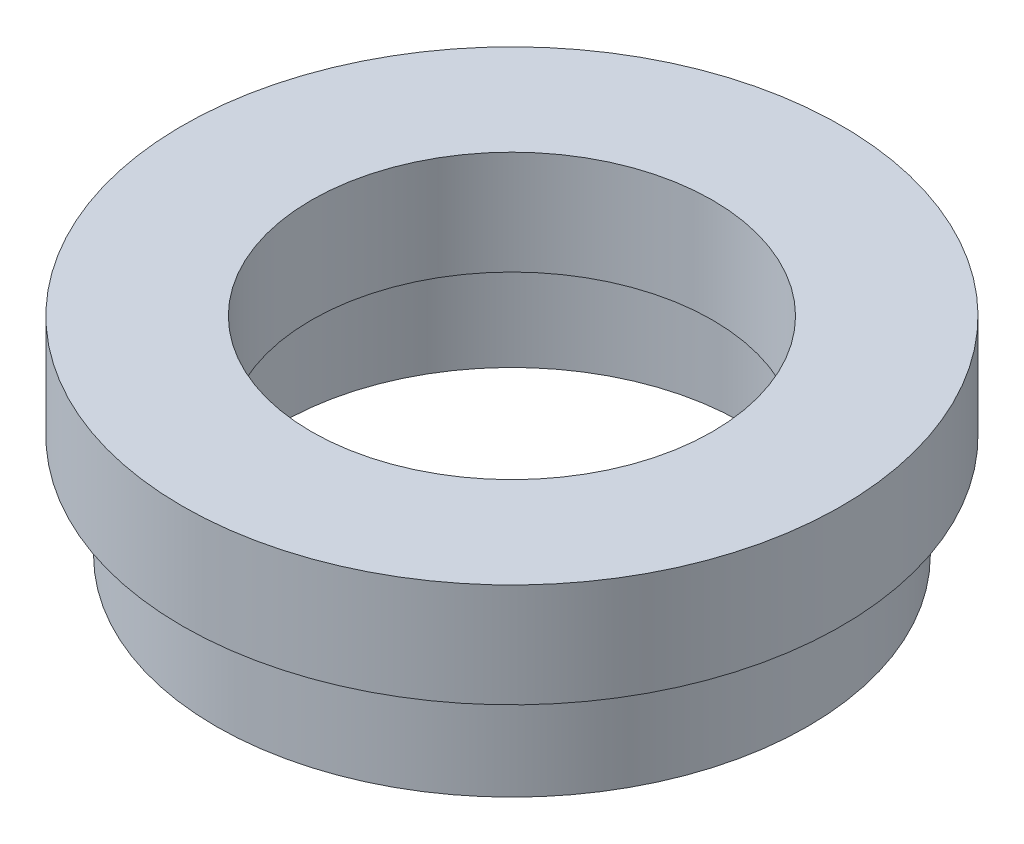
from build123d import *


with BuildPart() as part:
    # 草图1 → 旋转1 (revolve)
    with BuildSketch(Plane.XY, mode=Mode.PRIVATE) as revolve_1_sk:
        Polygon((14.25, 0), (11.1, 0), (11.1, 4), (11.7, 4), (11.7, 5), (9.66, 5), (9.66, 10), (15.875, 10), (15.875, 5), (13.75, 5), (13.75, 4), (14.25, 4), align=None)
    revolve(revolve_1_sk.sketch.rotate(Axis((0, 13.744680851, 0), (0, -1, 0)), 90), axis=Axis((0, 13.744680851, 0), (0, -1, 0)))  # turned: the seam where the file's is


solid = part.part
